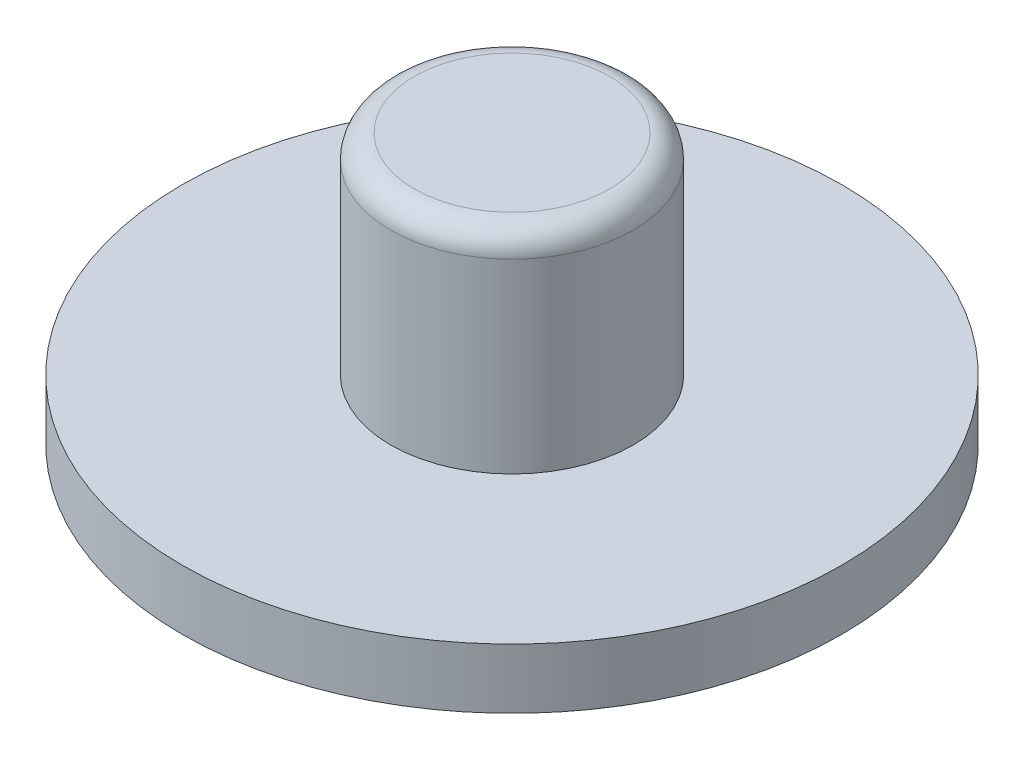
from build123d import *

# Parameters (mm, degrees)
SKETCH1_R           = 4.05
BOSS_EXTRUDE1_DEPTH = 3.5
FILLET1_R           = 0.79375
SKETCH2_R           = 11
BOSS_EXTRUDE2_DEPTH = 2


with BuildPart() as part:
    # Sketch1 → Boss-Extrude1 (new body, symmetric)
    with BuildSketch(Plane(origin=(0, 0, 0), x_dir=(1, 0, 0), z_dir=(0, 1, 0))):
        Circle(SKETCH1_R)
    extrude(amount=BOSS_EXTRUDE1_DEPTH, both=True)

    # Fillet1
    fillet1_edges = [part.edges().sort_by_distance(p)[0] for p in [
        (-4.05, 3.5, 0),
    ]]
    fillet(fillet1_edges, radius=FILLET1_R)

    # Sketch2 → Boss-Extrude2 (add)
    with BuildSketch(Plane.XZ.offset(3.5)):
        Circle(SKETCH2_R)
    extrude(amount=BOSS_EXTRUDE2_DEPTH)


solid = part.part
